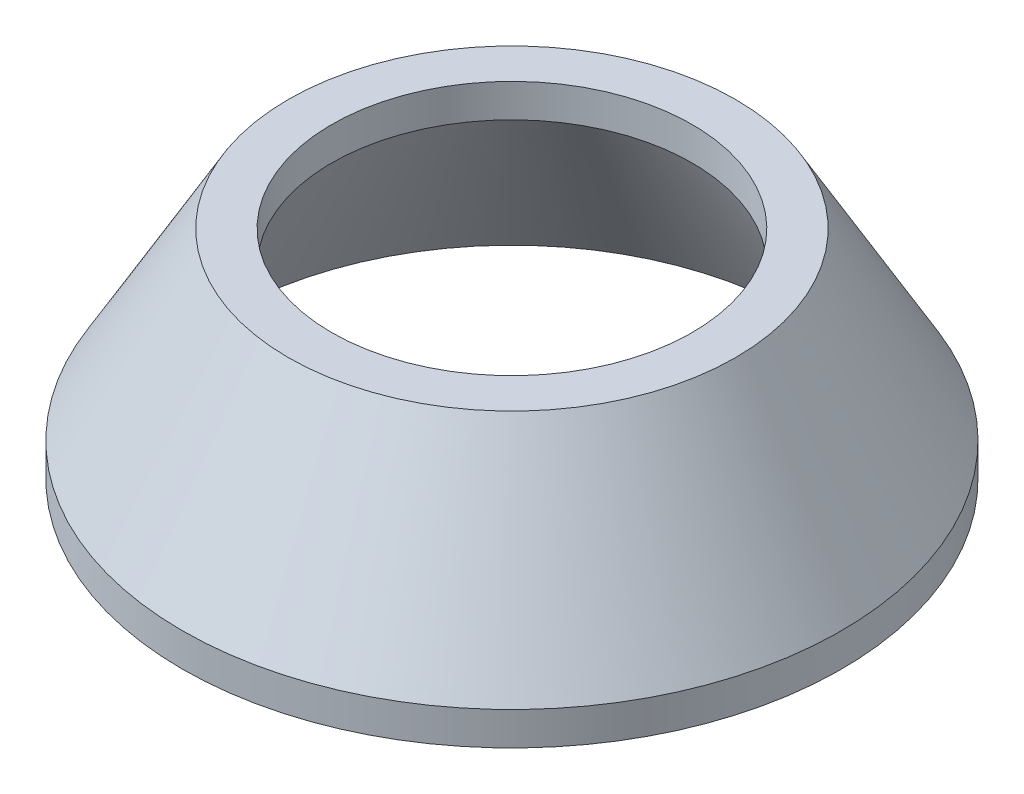
from build123d import *


with BuildPart() as part:
    # Sketch1 → Revolve1 (revolve)
    with BuildSketch(Plane.XY):
        Polygon((33.25, 40), (33.25, 33.856406461), (52.797005384, 0), (60.797005384, 0), (60.797005384, 6.143593539), (41.25, 40), align=None)
    revolve(axis=Axis((0, 26.383004513, 0), (0, -1, 0)))


solid = part.part
